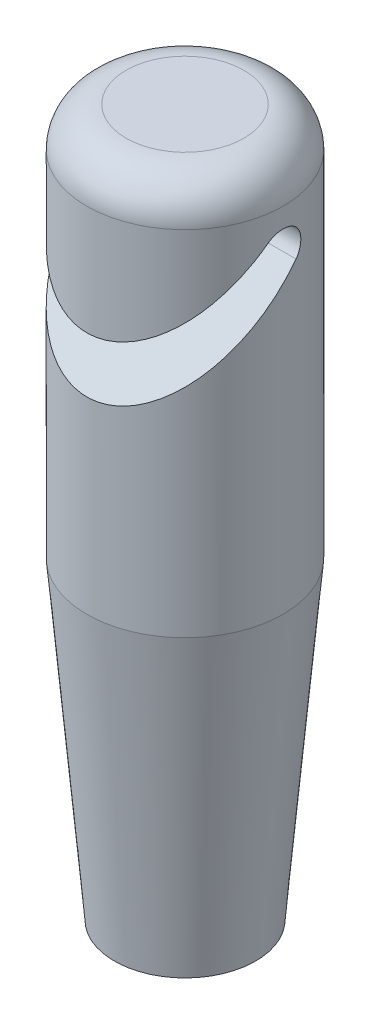
from build123d import *

# Parameters (mm, degrees)
SKETCH1_R               = 2.5
BOSS_EXTRUDE1_DEPTH     = 10
SKETCH2_R               = 2.5
BOSS_EXTRUDE2_DEPTH     = 8
BOSS_EXTRUDE2_TAPER     = 5
CUT_EXTRUDE1_START      = -8
SKETCH3_R               = 1.5
CUT_EXTRUDE1_DEPTH      = 8
FILLET1_R               = 1
CUT_EXTRUDE2_DEPTH      = 3.5000001
CUT_EXTRUDE2_DEPTH_BACK = 3.5000001


with BuildPart() as part:
    # Sketch1 → Boss-Extrude1 (new body)
    with BuildSketch(Plane(origin=(0, 0, 0), x_dir=(1, 0, 0), z_dir=(0, 1, 0))):
        Circle(SKETCH1_R)
    extrude(amount=BOSS_EXTRUDE1_DEPTH)

    # Sketch2 → Boss-Extrude2 (add)
    with BuildSketch(Plane.XZ):
        Circle(SKETCH2_R)
    extrude(amount=BOSS_EXTRUDE2_DEPTH, taper=BOSS_EXTRUDE2_TAPER)

    # Sketch3 → Cut-Extrude1 (cut)
    with BuildSketch(Plane.XZ.offset(8).offset(CUT_EXTRUDE1_START)):
        Circle(SKETCH3_R)
    extrude(amount=CUT_EXTRUDE1_DEPTH, mode=Mode.SUBTRACT)

    # Fillet1
    fillet1_edges = [part.edges().sort_by_distance(p)[0] for p in [
        (-2.5, 10, 0),
    ]]
    fillet(fillet1_edges, radius=FILLET1_R)

    # Sketch4 → Cut-Extrude2 (cut, two sides)
    with BuildSketch(Plane(origin=(0, 0, 0), x_dir=(0, 0, -1), z_dir=(1, 0, 0))) as cut_extrude2_sk:
        with BuildLine():
            Line((0.353553391, 7.646446609), (-6.418274977, 0.874618242))
            Line((-6.418274977, 0.874618242), (-6.418274977, 2.288831805))
            Line((-6.418274977, 2.288831805), (-0.353553391, 8.353553391))
            ThreePointArc((-0.353553391, 8.353553391), (0.353553391, 8.353553391), (0.353553391, 7.646446609))
        make_face()
    extrude(amount=CUT_EXTRUDE2_DEPTH, mode=Mode.SUBTRACT)
    extrude(cut_extrude2_sk.sketch, amount=-CUT_EXTRUDE2_DEPTH_BACK, mode=Mode.SUBTRACT)


solid = part.part
